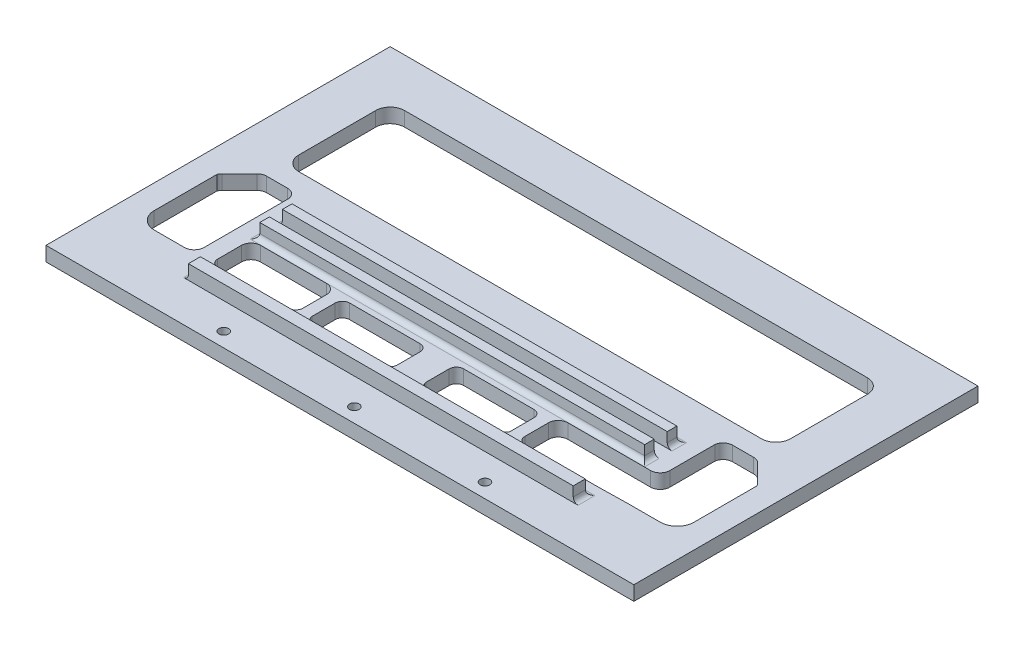
from build123d import *

# Parameters (mm, degrees)
SKETCH1_W           = 122.2
SKETCH1_H           = 65.54
BOSS_EXTRUDE1_DEPTH = 3
SKETCH2_W           = 80
SKETCH2_H           = 2
BOSS_EXTRUDE2_DEPTH = 10
FILLET1_R           = 1
SKETCH3_W           = 80
SKETCH3_H           = 2
CUT_EXTRUDE1_DEPTH  = 7
SKETCH4_W           = 80
SKETCH4_H           = 2.5
BOSS_EXTRUDE3_DEPTH = 3
FILLET2_R           = 1
CUT_EXTRUDE2_DEPTH  = 10
CUT_EXTRUDE3_DEPTH  = 10
SKETCH7_W           = 122.2
SKETCH7_H           = 3
BOSS_EXTRUDE4_DEPTH = 6
SKETCH8_R           = 1
CUT_EXTRUDE4_DEPTH  = 6
FILLET3_R           = 2


with BuildPart() as part:
    # Sketch1 → Boss-Extrude1 (new body)
    with BuildSketch(Plane(origin=(0, 0, 0), x_dir=(1, 0, 0), z_dir=(0, 1, 0))):
        Rectangle(SKETCH1_W, SKETCH1_H)
    extrude(amount=BOSS_EXTRUDE1_DEPTH)

    # Sketch2 → Boss-Extrude2 (add)
    with BuildSketch(Plane(origin=(0, 3, 0), x_dir=(1, 0, 0), z_dir=(0, 1, 0))):
        with Locations((0, -9.73)):
            Rectangle(SKETCH2_W, SKETCH2_H)
        with Locations((0, -14.43)):
            Rectangle(SKETCH2_W, SKETCH2_H)
    extrude(amount=BOSS_EXTRUDE2_DEPTH)

    # Fillet1
    fillet1_edges = [part.edges().sort_by_distance(p)[0] for p in [
        (40, 3, 14.43),
        (0, 3, 15.43),
        (-40, 3, 14.43),
        (40, 3, 9.73),
        (0, 3, 8.73),
        (-40, 3, 9.73),
    ]]
    fillet(fillet1_edges, radius=FILLET1_R)

    # Sketch3 → Cut-Extrude1 (cut)
    with BuildSketch(Plane(origin=(0, 13, 0), x_dir=(1, 0, 0), z_dir=(0, 1, 0))):
        with Locations((0, -9.73)):
            Rectangle(SKETCH3_W, SKETCH3_H)
        with Locations((0, -14.43)):
            Rectangle(SKETCH3_W, SKETCH3_H)
    extrude(amount=-CUT_EXTRUDE1_DEPTH, mode=Mode.SUBTRACT)

    # Sketch4 → Boss-Extrude3 (add)
    with BuildSketch(Plane(origin=(0, 3, 0), x_dir=(1, 0, 0), z_dir=(0, 1, 0))):
        with Locations((0, -29.02)):
            Rectangle(SKETCH4_W, SKETCH4_H)
    boss_extrude3 = extrude(amount=BOSS_EXTRUDE3_DEPTH)

    # Fillet2
    fillet2_edges = [part.edges().sort_by_distance(p)[0] for p in [
        (40, 3, 29.02),
        (0, 3, 27.77),
        (-40, 3, 29.02),
    ]]
    fillet(fillet2_edges, radius=FILLET2_R)

    # Mirror1: Boss-Extrude3 across plane
    add(boss_extrude3.mirror(Plane.ZY))

    # Sketch5 → Cut-Extrude2 (cut)
    with BuildSketch(Plane(origin=(0, 3, 0), x_dir=(1, 0, 0), z_dir=(0, 1, 0))):
        with BuildLine():
            Line((48.1, 22.77), (6.311514948, 22.77))
            Line((6.311514948, 22.77), (-48.1, 22.77))
            ThreePointArc((-48.1, 22.77), (-50.221320344, 21.891320344), (-51.1, 19.77))
            Line((-51.1, 19.77), (-51.1, 3.77))
            ThreePointArc((-51.1, 3.77), (-50.221320344, 1.648679656), (-48.1, 0.77))
            Line((-48.1, 0.77), (48.1, 0.77))
            ThreePointArc((48.1, 0.77), (50.221320344, 1.648679656), (51.1, 3.77))
            Line((51.1, 3.77), (51.1, 19.77))
            ThreePointArc((51.1, 19.77), (50.221320344, 21.891320344), (48.1, 22.77))
        make_face()
    extrude(amount=-CUT_EXTRUDE2_DEPTH, mode=Mode.SUBTRACT)

    # Sketch6 → Cut-Extrude3 (cut)
    with BuildSketch(Plane(origin=(0, 3, 0), x_dir=(1, 0, 0), z_dir=(0, 1, 0))):
        with BuildLine():
            ThreePointArc((24.574193631, -24.893622011), (23.513533459, -24.454282183), (23.074193631, -23.393622011))
            Line((23.074193631, -23.393622011), (23.074193631, -18.473462095))
            ThreePointArc((23.074193631, -18.473462095), (23.659980069, -17.059248532), (25.074193631, -16.473462095))
            Line((25.074193631, -16.473462095), (38.784700518, -16.473462095))
            Line((38.784700518, -16.473462095), (44.284700518, -16.473462095))
            Line((44.284700518, -16.473462095), (44.284700518, -5.054704437))
            ThreePointArc((44.284700518, -5.054704437), (44.964391332, -3.856403354), (46.257750275, -3.381927082))
            Line((46.257750275, -3.381927082), (50.626867349, -3.381927082))
            ThreePointArc((50.626867349, -3.381927082), (51.392234214, -3.534168016), (52.041080911, -3.967713519))
            Line((52.041080911, -3.967713519), (55.687864116, -7.614496724))
            ThreePointArc((55.687864116, -7.614496724), (55.921387017, -7.895147518), (56.1, -8.213573672))
            Line((56.1, -8.213573672), (56.1, -21.269749634))
            ThreePointArc((56.1, -21.269749634), (55.074873734, -23.744623369), (52.6, -24.769749634))
            Line((52.6, -24.769749634), (46.32782558, -24.769749634))
            Line((46.32782558, -24.769749634), (39.284700518, -24.893622011))
            Line((39.284700518, -24.893622011), (24.574193631, -24.893622011))
        make_face()
        with BuildLine():
            ThreePointArc((20.660852384, -23.893622011), (20.367959165, -24.600728792), (19.660852384, -24.893622011))
            Line((19.660852384, -24.893622011), (4.043952302, -24.893622011))
            ThreePointArc((4.043952302, -24.893622011), (3.336845521, -24.600728792), (3.043952302, -23.893622011))
            Line((3.043952302, -23.893622011), (3.043952302, -19.096324264))
            ThreePointArc((3.043952302, -19.096324264), (3.48329213, -18.035664092), (4.543952302, -17.596324264))
            Line((4.543952302, -17.596324264), (19.160852384, -17.596324264))
            ThreePointArc((19.160852384, -17.596324264), (20.221512556, -18.035664092), (20.660852384, -19.096324264))
            Line((20.660852384, -19.096324264), (20.660852384, -23.893622011))
        make_face()
        with BuildLine():
            ThreePointArc((-20.660852384, -19.096324264), (-20.221512556, -18.035664092), (-19.160852384, -17.596324264))
            Line((-19.160852384, -17.596324264), (-4.543952302, -17.596324264))
            ThreePointArc((-4.543952302, -17.596324264), (-3.48329213, -18.035664092), (-3.043952302, -19.096324264))
            Line((-3.043952302, -19.096324264), (-3.043952302, -23.893622011))
            ThreePointArc((-3.043952302, -23.893622011), (-3.336845521, -24.600728792), (-4.043952302, -24.893622011))
            Line((-4.043952302, -24.893622011), (-19.660852384, -24.893622011))
            ThreePointArc((-19.660852384, -24.893622011), (-20.367959165, -24.600728792), (-20.660852384, -23.893622011))
            Line((-20.660852384, -23.893622011), (-20.660852384, -19.096324264))
        make_face()
        with BuildLine():
            Line((-56.1, -21.269749634), (-56.1, -8.213573672))
            ThreePointArc((-56.1, -8.213573672), (-55.921387017, -7.895147518), (-55.687864116, -7.614496724))
            Line((-55.687864116, -7.614496724), (-52.041080911, -3.967713519))
            ThreePointArc((-52.041080911, -3.967713519), (-51.392234214, -3.534168016), (-50.626867349, -3.381927082))
            Line((-50.626867349, -3.381927082), (-46.257750275, -3.381927082))
            ThreePointArc((-46.257750275, -3.381927082), (-44.964391332, -3.856403354), (-44.284700518, -5.054704437))
            Line((-44.284700518, -5.054704437), (-44.284700518, -22.726624573))
            ThreePointArc((-44.284700518, -22.726624573), (-44.883117994, -24.171332159), (-46.32782558, -24.769749634))
            Line((-46.32782558, -24.769749634), (-52.6, -24.769749634))
            ThreePointArc((-52.6, -24.769749634), (-55.074873734, -23.744623369), (-56.1, -21.269749634))
        make_face()
        with BuildLine():
            Line((-39.284700518, -24.893622011), (-24.574193631, -24.893622011))
            ThreePointArc((-24.574193631, -24.893622011), (-23.513533459, -24.454282183), (-23.074193631, -23.393622011))
            Line((-23.074193631, -23.393622011), (-23.074193631, -18.473462095))
            ThreePointArc((-23.074193631, -18.473462095), (-23.659980069, -17.059248532), (-25.074193631, -16.473462095))
            Line((-25.074193631, -16.473462095), (-38.784700518, -16.473462095))
            ThreePointArc((-38.784700518, -16.473462095), (-40.198914081, -17.059248532), (-40.784700518, -18.473462095))
            Line((-40.784700518, -18.473462095), (-40.784700518, -23.393622011))
            ThreePointArc((-40.784700518, -23.393622011), (-40.34536069, -24.454282183), (-39.284700518, -24.893622011))
        make_face()
    extrude(amount=-CUT_EXTRUDE3_DEPTH, mode=Mode.SUBTRACT)

    # Sketch7 → Boss-Extrude4 (add)
    with BuildSketch(Plane.XY.offset(32.77)):
        with Locations((0, 1.5)):
            Rectangle(SKETCH7_W, SKETCH7_H)
    extrude(amount=BOSS_EXTRUDE4_DEPTH)

    # Sketch8 → Cut-Extrude4 (cut)
    with BuildSketch(Plane.XZ):
        with Locations((0, 35.77)):
            Circle(SKETCH8_R)
        with Locations((-27.15, 35.77)):
            Circle(SKETCH8_R)
        with Locations((27.15, 35.77)):
            Circle(SKETCH8_R)
    extrude(amount=-CUT_EXTRUDE4_DEPTH, mode=Mode.SUBTRACT)

    # Fillet3
    fillet3_edges = [part.edges().sort_by_distance(p)[0] for p in [
        (44.284700518, 1.5, 16.473462095),
    ]]
    fillet(fillet3_edges, radius=FILLET3_R)


solid = part.part
